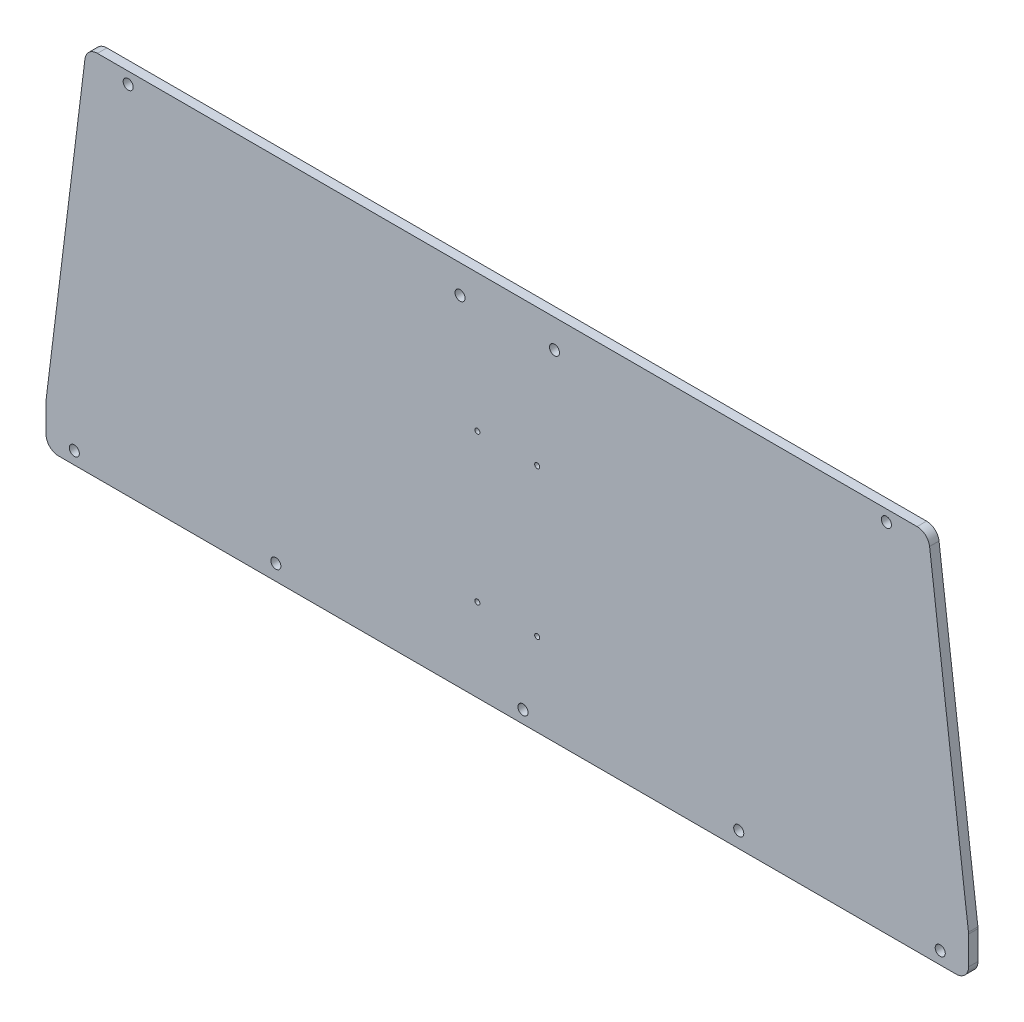
from build123d import *

# Parameters (mm, degrees)
BOSS_EXTRUDE1_DEPTH            = 3
F_3_2_3_2_DIAMETER_HOLE1_D     = 3.2
F_3_2_3_2_DIAMETER_HOLE1_DEPTH = 15
F_3_2_3_2_DIAMETER_HOLE1_TIP   = 0.96137699
F_1_6_1_6_DIAMETER_HOLE1_D     = 1.6
F_1_6_1_6_DIAMETER_HOLE1_DEPTH = 15
F_1_6_1_6_DIAMETER_HOLE1_TIP   = 0.480688495


with BuildPart() as part:
    # Sketch1 → Boss-Extrude1 (new body)
    with BuildSketch(Plane.XY):
        with BuildLine():
            Line((-11.618950039, 112.409005395), (11.618950039, 112.409005395))
            Line((11.618950039, 112.409005395), (130.207854482, 112.409005395))
            add(Edge.make_bspline(
                [(134.178039088, 108.917568146), (133.74675554, 112.409005395), (130.207854482, 112.409005395)],
                knots=[0.122173048, 0.122173048, 0.122173048, 1.570796327, 1.570796327, 1.570796327], degree=2, weights=[1, 0.748955721, 1]))
            Line((134.178039088, 108.917568146), (146.527006833, 8.947035697))
            add(Edge.make_bspline(
                [(146.556822227, 8.462484609), (146.556822227, 8.705666473), (146.527006833, 8.947035697)],
                knots=[0, 0, 0, 0.122173048, 0.122173048, 0.122173048], degree=2, weights=[1, 0.998134798, 1]))
            Line((146.556822227, 8.462484609), (146.556822227, -0.579261565))
            add(Edge.make_bspline(
                [(142.556822227, -4.555249901), (146.556822227, -4.555249901), (146.556822227, -0.579261565)],
                knots=[4.71238898, 4.71238898, 4.71238898, 6.283185307, 6.283185307, 6.283185307], degree=2, weights=[1, 0.707106781, 1]))
            Line((142.556822227, -4.555249901), (-142.556822227, -4.555249901))
            add(Edge.make_bspline(
                [(-146.556822227, -0.579261565), (-146.556822227, -4.555249901), (-142.556822227, -4.555249901)],
                knots=[3.141592654, 3.141592654, 3.141592654, 4.71238898, 4.71238898, 4.71238898], degree=2, weights=[1, 0.707106781, 1]))
            Line((-146.556822227, -0.579261565), (-146.556822227, 8.462484609))
            add(Edge.make_bspline(
                [(-146.527006833, 8.947035697), (-146.556822227, 8.705666473), (-146.556822227, 8.462484609)],
                knots=[3.019419606, 3.019419606, 3.019419606, 3.141592654, 3.141592654, 3.141592654], degree=2, weights=[1, 0.998134798, 1]))
            Line((-146.527006833, 8.947035697), (-134.178039088, 108.917568146))
            add(Edge.make_bspline(
                [(-130.207854482, 112.409005395), (-133.74675554, 112.409005395), (-134.178039088, 108.917568146)],
                knots=[1.570796327, 1.570796327, 1.570796327, 3.019419606, 3.019419606, 3.019419606], degree=2, weights=[1, 0.748955721, 1]))
            Line((-130.207854482, 112.409005395), (-11.618950039, 112.409005395))
        make_face()
    extrude(amount=-BOSS_EXTRUDE1_DEPTH)

    # Ø3.2 (3.2) Diameter Hole1
    with Locations(Plane(origin=(167.519332635, 69.709864468, 0), x_dir=(1, 0, 0), z_dir=(0, 0, 1))):
        with Locations((-47.07064809, 39.062428571), (-29.962510408, -70.289126033), (-93.981129185, -69.295128949), (-241.057536085, -69.295128949), (-305.076154862, -70.289126033), (-287.968017181, 39.062428571), (-182.519332635, 33.699140926), (-152.519332635, 33.699140926), (-162.519332635, -70.289126033)):
            Hole(F_3_2_3_2_DIAMETER_HOLE1_D / 2, depth=F_3_2_3_2_DIAMETER_HOLE1_DEPTH)
            with Locations((0, 0, -(F_3_2_3_2_DIAMETER_HOLE1_DEPTH + F_3_2_3_2_DIAMETER_HOLE1_TIP / 2))):  # 118° drill point
                Cone(0, F_3_2_3_2_DIAMETER_HOLE1_D / 2, F_3_2_3_2_DIAMETER_HOLE1_TIP, mode=Mode.SUBTRACT)

    # Ø1.6 (1.6) Diameter Hole1
    with Locations(Plane.XY):
        with Locations((-9.5, 68.809005395), (9.5, 68.809005395), (-9.5, 21.809005395), (9.5, 21.809005395)):
            Hole(F_1_6_1_6_DIAMETER_HOLE1_D / 2, depth=F_1_6_1_6_DIAMETER_HOLE1_DEPTH)
            with Locations((0, 0, -(F_1_6_1_6_DIAMETER_HOLE1_DEPTH + F_1_6_1_6_DIAMETER_HOLE1_TIP / 2))):  # 118° drill point
                Cone(0, F_1_6_1_6_DIAMETER_HOLE1_D / 2, F_1_6_1_6_DIAMETER_HOLE1_TIP, mode=Mode.SUBTRACT)


solid = part.part
